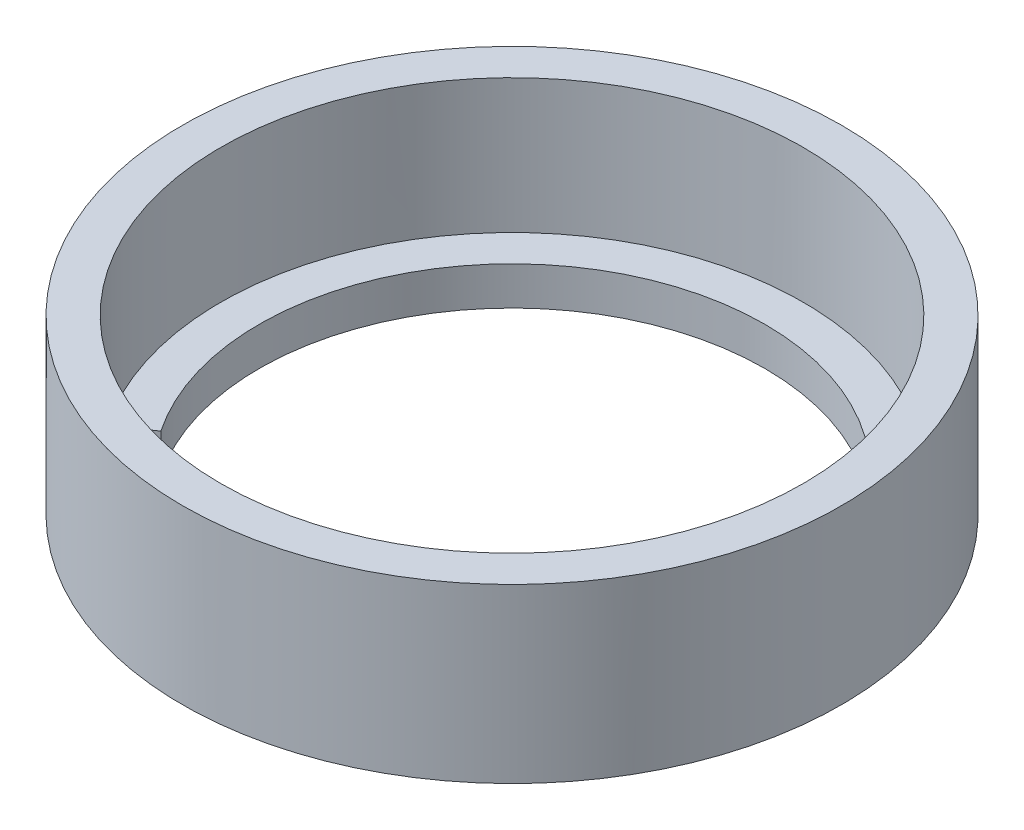
from build123d import *

# Parameters (mm, degrees)
SKETCH1_R           = 17.2
SKETCH1_R_2         = 15.2
BOSS_EXTRUDE1_DEPTH = 7
BOSS_EXTRUDE2_START = 2
SKETCH2_R           = 17.2
BOSS_EXTRUDE2_DEPTH = 2


with BuildPart() as part:
    # Sketch1 → Boss-Extrude1 (new body)
    with BuildSketch(Plane(origin=(0, 0, 0), x_dir=(1, 0, 0), z_dir=(0, 1, 0))):
        Circle(SKETCH1_R)
        Circle(SKETCH1_R_2, mode=Mode.SUBTRACT)
    extrude(amount=BOSS_EXTRUDE1_DEPTH)

    # Sketch2 → Boss-Extrude2 (add)
    with BuildSketch(Plane.XZ.offset(BOSS_EXTRUDE2_START)):
        Circle(SKETCH2_R)
        with BuildLine():
            Line((-10.9345628, 7.394277271), (-12.59131474, 8.514622313))
            ThreePointArc((-12.59131474, 8.514622313), (-8.934335835, 12.297058314), (-4.206956798, 14.606214927))
            Line((-4.206956798, 14.606214927), (-3.653409851, 12.684344542))
            ThreePointArc((-3.653409851, 12.684344542), (0, 13.2), (3.653409851, 12.684344542))
            Line((3.653409851, 12.684344542), (4.206956798, 14.606214927))
            ThreePointArc((4.206956798, 14.606214927), (8.934335835, 12.297058314), (12.59131474, 8.514622313))
            Line((12.59131474, 8.514622313), (10.9345628, 7.394277271))
            ThreePointArc((10.9345628, 7.394277271), (0, -13.2), (-10.9345628, 7.394277271))
        make_face(mode=Mode.SUBTRACT)
    extrude(amount=-BOSS_EXTRUDE2_DEPTH)


solid = part.part
